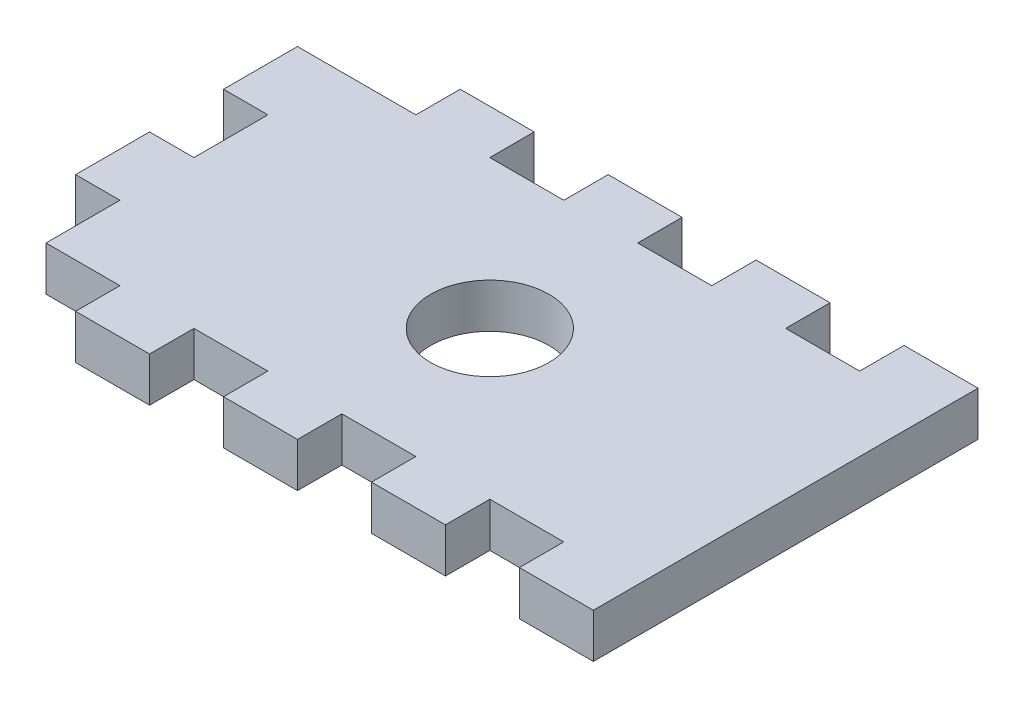
from build123d import *

# Parameters (mm, degrees)
SKETCH1_W           = 40
SKETCH1_H           = 26
BOSS_EXTRUDE1_DEPTH = 1.5
SKETCH2_R           = 4
CUT_EXTRUDE1_DEPTH  = 3
SKETCH8_W           = 5
SKETCH8_H           = 3
BOSS_EXTRUDE7_DEPTH = 3
SKETCH9_W           = 5
SKETCH9_H           = 3
CUT_EXTRUDE2_DEPTH  = 3


with BuildPart() as part:
    # Sketch1 → Boss-Extrude1 (new body, symmetric)
    with BuildSketch(Plane(origin=(0, 0, 0), x_dir=(1, 0, 0), z_dir=(0, 1, 0))):
        Rectangle(SKETCH1_W, SKETCH1_H)
    extrude(amount=BOSS_EXTRUDE1_DEPTH, both=True)

    # Sketch2 → Cut-Extrude1 (cut)
    with BuildSketch(Plane.XZ.offset(1.5)):
        Circle(SKETCH2_R)
    extrude(amount=-CUT_EXTRUDE1_DEPTH, mode=Mode.SUBTRACT)

    # Sketch8 → Boss-Extrude7 (add)
    with BuildSketch(Plane.ZY.offset(20)):
        with Locations((-7.5, 0)):
            Rectangle(SKETCH8_W, SKETCH8_H)
        with Locations((2.5, 0)):
            Rectangle(SKETCH8_W, SKETCH8_H)
    extrude(amount=BOSS_EXTRUDE7_DEPTH)

    # Sketch9 → Cut-Extrude2 (cut)
    with BuildSketch(Plane.XZ.offset(1.5)):
        with Locations((-17.5, -11.5)):
            Rectangle(SKETCH9_W, SKETCH9_H)
        with Locations((-7.5, -11.5)):
            Rectangle(SKETCH9_W, SKETCH9_H)
        with Locations((-17.5, 11.5)):
            Rectangle(SKETCH9_W, SKETCH9_H)
        with Locations((-7.5, 11.5)):
            Rectangle(SKETCH9_W, SKETCH9_H)
        with Locations((2.5, 11.5)):
            Rectangle(SKETCH9_W, SKETCH9_H)
        with Locations((12.5, 11.5)):
            Rectangle(SKETCH9_W, SKETCH9_H)
        with Locations((2.5, -11.5)):
            Rectangle(SKETCH9_W, SKETCH9_H)
        with Locations((12.5, -11.5)):
            Rectangle(SKETCH9_W, SKETCH9_H)
    extrude(amount=-CUT_EXTRUDE2_DEPTH, mode=Mode.SUBTRACT)


solid = part.part
